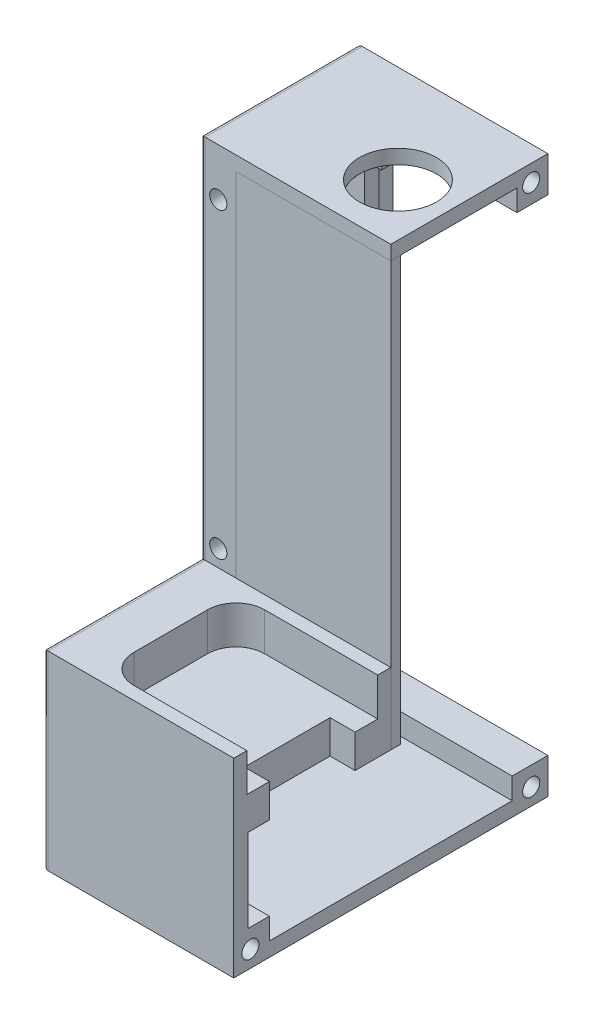
from build123d import *

# Parameters (mm, degrees)
SKETCH_1_W               = 33
SKETCH_1_H               = 25
SKETCH_1_W_2             = 23
SKETCH_1_H_2             = 117
SKETCH_1_W_3             = 10
EXTRUDE_1_DEPTH          = 60
SKETCH_2_W               = 45
SKETCH_2_H               = 62
CUT_EXTRUDE_1_DEPTH      = 10
SKETCH_3_R               = 8.1
CUT_EXTRUDE_2_DEPTH      = 10
SKETCH_4_W               = 45
SKETCH_4_H               = 40
CUT_EXTRUDE_3_DEPTH      = 58.5
SKETCH_5_W               = 60
SKETCH_5_H               = 33
EXTRUDE_2_DEPTH          = 15
EXTRUDE_3_DEPTH          = 7
SKETCH_7_W               = 45
SKETCH_7_H               = 66.5
CUT_EXTRUDE_4_DEPTH      = 20
SKETCH_8_W               = 45
SKETCH_8_H               = 2
EXTRUDE_4_DEPTH          = 89
SKETCH_9_R               = 1.8
CUT_EXTRUDE_5_DEPTH      = 61
SKETCH_10_R              = 1.8
CUT_EXTRUDE_6_DEPTH      = 34
CUT_EXTRUDE_6_DEPTH_BACK = 34
SKETCH_12_R              = 1.8
CUT_EXTRUDE_7_DEPTH      = 3
CUT_EXTRUDE_9_DEPTH      = 20
SKETCH_17_W              = 32.5
SKETCH_17_H              = 51
CUT_EXTRUDE_11_DEPTH     = 4.5
SKETCH_18_W              = 32.5
SKETCH_18_H              = 17.5
CUT_EXTRUDE_12_DEPTH     = 4.5
SKETCH_19_W              = 25.5
SKETCH_19_H              = 62
CUT_EXTRUDE_13_DEPTH     = 3
SKETCH_20_W              = 6.5
SKETCH_20_H              = 4.5
CUT_EXTRUDE_14_DEPTH     = 22
FILLET_1_R               = 1


with BuildPart() as part:
    # ｽｹｯﾁ1 → ﾎﾞｽ - 押し出し1 (new body)
    with BuildSketch(Plane(origin=(0, 0, 0), x_dir=(0, 0, -1), z_dir=(1, 0, 0))):
        with Locations((-16.5, -12.5)):
            Rectangle(SKETCH_1_W, SKETCH_1_H)
        with Locations((11.5, 33.5)):
            Rectangle(SKETCH_1_W_2, SKETCH_1_H_2)
        with Locations((28, 33.5)):
            Rectangle(SKETCH_1_W_3, SKETCH_1_H_2)
    extrude(amount=EXTRUDE_1_DEPTH)

    # ｽｹｯﾁ2 → ｶｯﾄ - 押し出し1 (cut)
    with BuildSketch(Plane(origin=(0, 0, -33), x_dir=(-1, 0, 0), z_dir=(0, 0, -1))):
        with Locations((-30, 53.5)):
            Rectangle(SKETCH_2_W, SKETCH_2_H)
    extrude(amount=-CUT_EXTRUDE_1_DEPTH, mode=Mode.SUBTRACT)

    # ｽｹｯﾁ3 → ｶｯﾄ - 押し出し2 (cut)
    with BuildSketch(Plane(origin=(0, 92, 0), x_dir=(1, 0, 0), z_dir=(0, 1, 0))):
        with Locations((29, 12.5)):
            Circle(SKETCH_3_R)
    extrude(amount=-CUT_EXTRUDE_2_DEPTH, mode=Mode.SUBTRACT)

    # ｽｹｯﾁ4 → ｶｯﾄ - 押し出し3 (cut)
    with BuildSketch(Plane(origin=(0, 0, -33), x_dir=(-1, 0, 0), z_dir=(0, 0, -1))):
        with Locations((-30, 2.5)):
            Rectangle(SKETCH_4_W, SKETCH_4_H)
    extrude(amount=-CUT_EXTRUDE_3_DEPTH, mode=Mode.SUBTRACT)

    # ｽｹｯﾁ5 → ﾎﾞｽ - 押し出し2 (add)
    with BuildSketch(Plane(origin=(0, 0, 0), x_dir=(1, 0, 0), z_dir=(0, 1, 0))):
        with Locations((30, -16.5)):
            Rectangle(SKETCH_5_W, SKETCH_5_H)
        with BuildLine():
            Line((41.75, -2.75), (16.25, -2.75))
            ThreePointArc((16.25, -2.75), (12.007359313, -4.507359313), (10.25, -8.75))
            Line((10.25, -8.75), (10.25, -24.25))
            ThreePointArc((10.25, -24.25), (12.007359313, -28.492640687), (16.25, -30.25))
            Line((16.25, -30.25), (41.75, -30.25))
            ThreePointArc((41.75, -30.25), (45.992640687, -28.492640687), (47.75, -24.25))
            Line((47.75, -24.25), (47.75, -8.75))
            ThreePointArc((47.75, -8.75), (45.992640687, -4.507359313), (41.75, -2.75))
        make_face(mode=Mode.SUBTRACT)
    extrude(amount=EXTRUDE_2_DEPTH)

    # ｽｹｯﾁ6 → ﾎﾞｽ - 押し出し3 (add)
    with BuildSketch(Plane(origin=(0, 0, 0), x_dir=(1, 0, 0), z_dir=(0, 1, 0))):
        with BuildLine():
            Line((10.381652703, -25.5), (34.75, -25.5))
            Line((34.75, -25.5), (34.75, -7.5))
            Line((34.75, -7.5), (34.75, -2.75))
            Line((34.75, -2.75), (16.25, -2.75))
            ThreePointArc((16.25, -2.75), (12.007359313, -4.507359313), (10.25, -8.75))
            Line((10.25, -8.75), (10.25, -24.25))
            ThreePointArc((10.25, -24.25), (10.283003947, -24.878456927), (10.381652703, -25.5))
        make_face()
        with BuildLine():
            Line((16.25, -30.25), (34.75, -30.25))
            Line((34.75, -30.25), (34.75, -25.5))
            Line((34.75, -25.5), (10.381652703, -25.5))
            ThreePointArc((10.381652703, -25.5), (12.475082782, -28.913689527), (16.25, -30.25))
        make_face()
        with BuildLine():
            Line((34.75, -25.5), (34.75, -30.25))
            Line((34.75, -30.25), (41.75, -30.25))
            ThreePointArc((41.75, -30.25), (42.251757562, -30.228983137), (42.75, -30.166079783))
            Line((42.75, -30.166079783), (42.75, -25.5))
            Line((42.75, -25.5), (34.75, -25.5))
        make_face()
        with BuildLine():
            Line((42.75, -7.5), (42.75, -25.5))
            Line((42.75, -25.5), (47.618347297, -25.5))
            ThreePointArc((47.618347297, -25.5), (47.716996053, -24.878456927), (47.75, -24.25))
            Line((47.75, -24.25), (47.75, -8.75))
            ThreePointArc((47.75, -8.75), (46.332575695, -4.877016654), (42.75, -2.833920217))
            Line((42.75, -2.833920217), (42.75, -7.5))
        make_face()
        with BuildLine():
            Line((47.618347297, -25.5), (42.75, -25.5))
            Line((42.75, -25.5), (42.75, -30.166079783))
            ThreePointArc((42.75, -30.166079783), (45.901701312, -28.581671296), (47.618347297, -25.5))
        make_face()
        with BuildLine():
            Line((34.75, -2.75), (34.75, -7.5))
            Line((34.75, -7.5), (42.75, -7.5))
            Line((42.75, -7.5), (42.75, -2.833920217))
            ThreePointArc((42.75, -2.833920217), (42.251757562, -2.771016863), (41.75, -2.75))
            Line((41.75, -2.75), (34.75, -2.75))
        make_face()
    extrude(amount=EXTRUDE_3_DEPTH)

    # ｽｹｯﾁ7 → ｶｯﾄ - 押し出し4 (cut)
    with BuildSketch(Plane.XY):
        with Locations((30, 55.75)):
            Rectangle(SKETCH_7_W, SKETCH_7_H)
    extrude(amount=-CUT_EXTRUDE_4_DEPTH, mode=Mode.SUBTRACT)

    # ｽｹｯﾁ9 → ｶｯﾄ - 押し出し5 (cut, through all)
    with BuildSketch(Plane.ZY):
        with Locations((-29.5, 88.5)):
            Circle(SKETCH_9_R)
        with Locations((-29.5, -21.5)):
            Circle(SKETCH_9_R)
        with Locations((29.5, -21.5)):
            Circle(SKETCH_9_R)
    extrude(amount=-CUT_EXTRUDE_5_DEPTH, mode=Mode.SUBTRACT)

    # ｽｹｯﾁ10 → ｶｯﾄ - 押し出し6 (cut, two sides)
    with BuildSketch(Plane.XY) as cut_extrude_6_sk:
        with Locations((3.75, 82)):
            Circle(SKETCH_10_R)
        with Locations((56.25, 82)):
            Circle(SKETCH_10_R)
        with Locations((56.25, 18.5)):
            Circle(SKETCH_10_R)
        with Locations((3.75, 18.5)):
            Circle(SKETCH_10_R)
    extrude(amount=CUT_EXTRUDE_6_DEPTH, mode=Mode.SUBTRACT)
    extrude(cut_extrude_6_sk.sketch, amount=-CUT_EXTRUDE_6_DEPTH_BACK, mode=Mode.SUBTRACT)

    # ｽｹｯﾁ12 → ｶｯﾄ - 押し出し7 (cut)
    with BuildSketch(Plane(origin=(0, 0, -23), x_dir=(-1, 0, 0), z_dir=(0, 0, -1))):
        with Locations((-49, 81.5)):
            Circle(SKETCH_12_R)
        with Locations((-11, 81.5)):
            Circle(SKETCH_12_R)
        with Locations((-11, 39.5)):
            Circle(SKETCH_12_R)
        with Locations((-49, 39.5)):
            Circle(SKETCH_12_R)
    extrude(amount=-CUT_EXTRUDE_7_DEPTH, mode=Mode.SUBTRACT)


with BuildPart() as body_2:
    # ｽｹｯﾁ8 → ﾎﾞｽ - 押し出し4 (new body)
    with BuildSketch(Plane(origin=(0, 89, 0), x_dir=(-1, 0, 0), z_dir=(0, -1, 0))):
        with Locations((-30, 1)):
            Rectangle(SKETCH_8_W, SKETCH_8_H)
    extrude(amount=EXTRUDE_4_DEPTH)


with BuildPart() as cut_extrude_9_tool:
    # ｽｹｯﾁ15 → ｶｯﾄ - 押し出し9 (new body)
    with BuildSketch(Plane(origin=(60, 0, 0), x_dir=(0, 0, -1), z_dir=(1, 0, 0))):
        Polygon((-33, 15), (-33, -25), (33, -25), (33, 92), (0, 92), (0, 15), align=None)
    extrude(amount=-CUT_EXTRUDE_9_DEPTH)


with BuildPart() as part_1:
    add(part.part)

    # ｶｯﾄ - 押し出し9: cut by cut_extrude_9_tool
    add(cut_extrude_9_tool.part, mode=Mode.SUBTRACT)

    # ｽｹｯﾁ17 → ｶｯﾄ - 押し出し11 (cut)
    with BuildSketch(Plane(origin=(0, -17.5, 0), x_dir=(1, 0, 0), z_dir=(0, 1, 0))):
        with Locations((23.75, 0)):
            Rectangle(SKETCH_17_W, SKETCH_17_H)
    extrude(amount=-CUT_EXTRUDE_11_DEPTH, mode=Mode.SUBTRACT)

    # ｽｹｯﾁ18 → ｶｯﾄ - 押し出し12 (cut)
    with BuildSketch(Plane(origin=(0, 0, 25.5), x_dir=(-1, 0, 0), z_dir=(0, 0, -1))):
        with Locations((-23.75, -8.75)):
            Rectangle(SKETCH_18_W, SKETCH_18_H)
    extrude(amount=-CUT_EXTRUDE_12_DEPTH, mode=Mode.SUBTRACT)

    # ｽｹｯﾁ19 → ｶｯﾄ - 押し出し13 (cut)
    with BuildSketch(Plane(origin=(0, 0, -23), x_dir=(-1, 0, 0), z_dir=(0, 0, -1))):
        with Locations((-27.25, 53.5)):
            Rectangle(SKETCH_19_W, SKETCH_19_H)
    extrude(amount=-CUT_EXTRUDE_13_DEPTH, mode=Mode.SUBTRACT)

    # ｽｹｯﾁ20 → ｶｯﾄ - 押し出し14 (cut)
    with BuildSketch(Plane(origin=(40, 0, 0), x_dir=(0, 0, -1), z_dir=(1, 0, 0))):
        with Locations((23.25, 86.75)):
            Rectangle(SKETCH_20_W, SKETCH_20_H)
    extrude(amount=-CUT_EXTRUDE_14_DEPTH, mode=Mode.SUBTRACT)

    # ﾌｨﾚｯﾄ1
    fillet_1_edges = [part_1.edges().sort_by_distance(p)[0] for p in [
        (0, -5, 33),
        (0, 15, 16.5),
        (0, 53.5, 0),
        (0, 92, -16.5),
        (0, 33.5, -33),
        (0, -25, 0),
    ]]
    fillet(fillet_1_edges, radius=FILLET_1_R)


with BuildPart() as body_2_1:
    add(body_2.part)

    # ｶｯﾄ - 押し出し9: cut by cut_extrude_9_tool
    add(cut_extrude_9_tool.part, mode=Mode.SUBTRACT)


solid = Compound([part_1.part, body_2_1.part])
